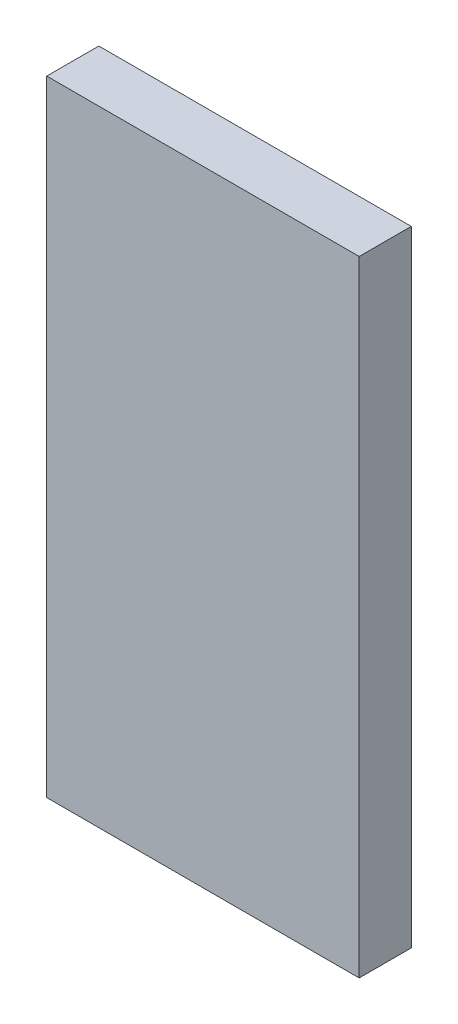
from build123d import *

# Parameters (mm, degrees)
SKETCH1_W           = 38.1
SKETCH1_H           = 76.2
BOSS_EXTRUDE1_DEPTH = 6.35


with BuildPart() as part:
    # Sketch1 → Boss-Extrude1 (new body)
    with BuildSketch(Plane.XY):
        Rectangle(SKETCH1_W, SKETCH1_H)
    extrude(amount=BOSS_EXTRUDE1_DEPTH)


solid = part.part
